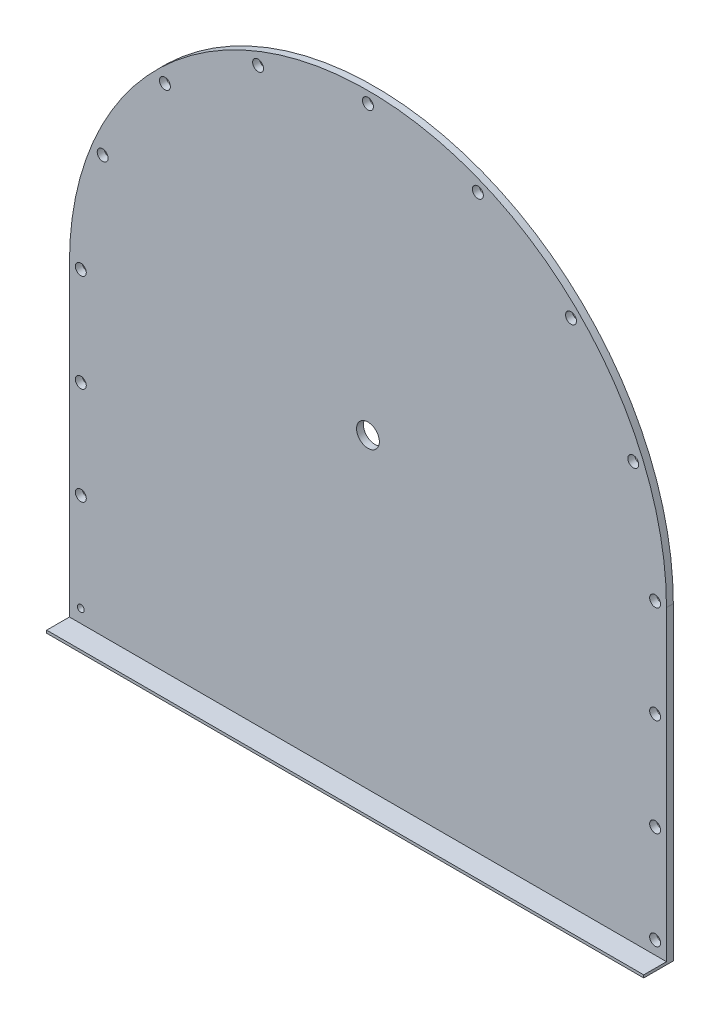
from build123d import *

# Parameters (mm, degrees)
EXTRUDE_1_DEPTH     = 1312
CUT_EXTRUDE_1_REACH = 17
SKETCH_2_R          = 25
CUT_EXTRUDE_2_REACH = 17
CUT_EXTRUDE_3_REACH = 17
SKETCH_4_R          = 7.5
SKETCH_4_R_2        = 12


with BuildPart() as part:
    # 스케치1 → 보스-돌출1 (new body)
    with BuildSketch(Plane(origin=(0, 0, 0), x_dir=(0, 0, -1), z_dir=(1, 0, 0))):
        Polygon((0, 0), (65, 0), (65, 1336), (50, 1336), (50, 6), (0, 6), align=None)
    extrude(amount=EXTRUDE_1_DEPTH)

    # 스케치2 → 컷-돌출1 (cut, up to next)
    with BuildSketch(Plane.XY.offset(-50), mode=Mode.PRIVATE) as cut_extrude_1_sk1:
        with Locations((656, 680)):
            Circle(SKETCH_2_R)
    cut_extrude_1_tool1 = extrude(cut_extrude_1_sk1.sketch, amount=-CUT_EXTRUDE_1_REACH, mode=Mode.PRIVATE) & part.part
    add(cut_extrude_1_tool1.solids().sort_by_distance((656, 680, -50))[0], mode=Mode.SUBTRACT)

    # 스케치3 → 컷-돌출2 (cut, up to next)
    with BuildSketch(Plane.XY.offset(-50), mode=Mode.PRIVATE) as cut_extrude_2_sk1:
        with BuildLine():
            ThreePointArc((0, 680), (192.137951542, 1143.862048458), (656, 1336))
            Line((656, 1336), (0, 1336))
            Line((0, 1336), (0, 680))
        make_face()
    cut_extrude_2_tool1 = extrude(cut_extrude_2_sk1.sketch, amount=-CUT_EXTRUDE_2_REACH, mode=Mode.PRIVATE) & part.part
    add(cut_extrude_2_tool1.solids().sort_by_distance((146.529368, 1189.470632, -50))[0], mode=Mode.SUBTRACT)
    # 스케치3 → 컷-돌출2 (cut, up to next)
    with BuildSketch(Plane.XY.offset(-50), mode=Mode.PRIVATE) as cut_extrude_2_sk2:
        with BuildLine():
            Line((1312, 680), (1312, 1336))
            Line((1312, 1336), (656, 1336))
            ThreePointArc((656, 1336), (1119.862048458, 1143.862048458), (1312, 680))
        make_face()
    cut_extrude_2_tool2 = extrude(cut_extrude_2_sk2.sketch, amount=-CUT_EXTRUDE_2_REACH, mode=Mode.PRIVATE) & part.part
    add(cut_extrude_2_tool2.solids().sort_by_distance((1165.470632, 1189.470632, -50))[0], mode=Mode.SUBTRACT)

    # 스케치4 → 컷-돌출3 (cut, up to next)
    with BuildSketch(Plane.XY.offset(-50), mode=Mode.PRIVATE) as cut_extrude_3_sk1:
        with Locations((25, 35)):
            Circle(SKETCH_4_R)
    cut_extrude_3_tool1 = extrude(cut_extrude_3_sk1.sketch, amount=-CUT_EXTRUDE_3_REACH, mode=Mode.PRIVATE) & part.part
    add(cut_extrude_3_tool1.solids().sort_by_distance((25, 35, -50))[0], mode=Mode.SUBTRACT)
    # 스케치4 → 컷-돌출3 (cut, up to next)
    with BuildSketch(Plane.XY.offset(-50), mode=Mode.PRIVATE) as cut_extrude_3_sk2:
        with Locations((25, 250)):
            Circle(SKETCH_4_R_2)
    cut_extrude_3_tool2 = extrude(cut_extrude_3_sk2.sketch, amount=-CUT_EXTRUDE_3_REACH, mode=Mode.PRIVATE) & part.part
    add(cut_extrude_3_tool2.solids().sort_by_distance((25, 250, -50))[0], mode=Mode.SUBTRACT)
    # 스케치4 → 컷-돌출3 (cut, up to next)
    with BuildSketch(Plane.XY.offset(-50), mode=Mode.PRIVATE) as cut_extrude_3_sk3:
        with Locations((25, 465)):
            Circle(SKETCH_4_R_2)
    cut_extrude_3_tool3 = extrude(cut_extrude_3_sk3.sketch, amount=-CUT_EXTRUDE_3_REACH, mode=Mode.PRIVATE) & part.part
    add(cut_extrude_3_tool3.solids().sort_by_distance((25, 465, -50))[0], mode=Mode.SUBTRACT)
    # 스케치4 → 컷-돌출3 (cut, up to next)
    with BuildSketch(Plane.XY.offset(-50), mode=Mode.PRIVATE) as cut_extrude_3_sk4:
        with Locations((25, 680)):
            Circle(SKETCH_4_R_2)
    cut_extrude_3_tool4 = extrude(cut_extrude_3_sk4.sketch, amount=-CUT_EXTRUDE_3_REACH, mode=Mode.PRIVATE) & part.part
    add(cut_extrude_3_tool4.solids().sort_by_distance((25, 680, -50))[0], mode=Mode.SUBTRACT)
    # 스케치4 → 컷-돌출3 (cut, up to next)
    with BuildSketch(Plane.XY.offset(-50), mode=Mode.PRIVATE) as cut_extrude_3_sk5:
        with Locations((73.032014985, 921.473245822)):
            Circle(SKETCH_4_R_2)
    cut_extrude_3_tool5 = extrude(cut_extrude_3_sk5.sketch, amount=-CUT_EXTRUDE_3_REACH, mode=Mode.PRIVATE) & part.part
    add(cut_extrude_3_tool5.solids().sort_by_distance((73.032015, 921.473246, -50))[0], mode=Mode.SUBTRACT)
    # 스케치4 → 컷-돌출3 (cut, up to next)
    with BuildSketch(Plane.XY.offset(-50), mode=Mode.PRIVATE) as cut_extrude_3_sk6:
        with Locations((209.815621071, 1126.184378929)):
            Circle(SKETCH_4_R_2)
    cut_extrude_3_tool6 = extrude(cut_extrude_3_sk6.sketch, amount=-CUT_EXTRUDE_3_REACH, mode=Mode.PRIVATE) & part.part
    add(cut_extrude_3_tool6.solids().sort_by_distance((209.815621, 1126.184379, -50))[0], mode=Mode.SUBTRACT)
    # 스케치4 → 컷-돌출3 (cut, up to next)
    with BuildSketch(Plane.XY.offset(-50), mode=Mode.PRIVATE) as cut_extrude_3_sk7:
        with Locations((414.526754178, 1262.967985015)):
            Circle(SKETCH_4_R_2)
    cut_extrude_3_tool7 = extrude(cut_extrude_3_sk7.sketch, amount=-CUT_EXTRUDE_3_REACH, mode=Mode.PRIVATE) & part.part
    add(cut_extrude_3_tool7.solids().sort_by_distance((414.526754, 1262.967985, -50))[0], mode=Mode.SUBTRACT)
    # 스케치4 → 컷-돌출3 (cut, up to next)
    with BuildSketch(Plane.XY.offset(-50), mode=Mode.PRIVATE) as cut_extrude_3_sk8:
        with Locations((656, 1311)):
            Circle(SKETCH_4_R_2)
    cut_extrude_3_tool8 = extrude(cut_extrude_3_sk8.sketch, amount=-CUT_EXTRUDE_3_REACH, mode=Mode.PRIVATE) & part.part
    add(cut_extrude_3_tool8.solids().sort_by_distance((656, 1311, -50))[0], mode=Mode.SUBTRACT)
    # 스케치4 → 컷-돌출3 (cut, up to next)
    with BuildSketch(Plane.XY.offset(-50), mode=Mode.PRIVATE) as cut_extrude_3_sk9:
        with Locations((897.473245822, 1262.967985015)):
            Circle(SKETCH_4_R_2)
    cut_extrude_3_tool9 = extrude(cut_extrude_3_sk9.sketch, amount=-CUT_EXTRUDE_3_REACH, mode=Mode.PRIVATE) & part.part
    add(cut_extrude_3_tool9.solids().sort_by_distance((897.473246, 1262.967985, -50))[0], mode=Mode.SUBTRACT)
    # 스케치4 → 컷-돌출3 (cut, up to next)
    with BuildSketch(Plane.XY.offset(-50), mode=Mode.PRIVATE) as cut_extrude_3_sk10:
        with Locations((1102.184378929, 1126.184378929)):
            Circle(SKETCH_4_R_2)
    cut_extrude_3_tool10 = extrude(cut_extrude_3_sk10.sketch, amount=-CUT_EXTRUDE_3_REACH, mode=Mode.PRIVATE) & part.part
    add(cut_extrude_3_tool10.solids().sort_by_distance((1102.184379, 1126.184379, -50))[0], mode=Mode.SUBTRACT)
    # 스케치4 → 컷-돌출3 (cut, up to next)
    with BuildSketch(Plane.XY.offset(-50), mode=Mode.PRIVATE) as cut_extrude_3_sk11:
        with Locations((1238.967985015, 921.473245822)):
            Circle(SKETCH_4_R_2)
    cut_extrude_3_tool11 = extrude(cut_extrude_3_sk11.sketch, amount=-CUT_EXTRUDE_3_REACH, mode=Mode.PRIVATE) & part.part
    add(cut_extrude_3_tool11.solids().sort_by_distance((1238.967985, 921.473246, -50))[0], mode=Mode.SUBTRACT)
    # 스케치4 → 컷-돌출3 (cut, up to next)
    with BuildSketch(Plane.XY.offset(-50), mode=Mode.PRIVATE) as cut_extrude_3_sk12:
        with Locations((1287, 680)):
            Circle(SKETCH_4_R_2)
    cut_extrude_3_tool12 = extrude(cut_extrude_3_sk12.sketch, amount=-CUT_EXTRUDE_3_REACH, mode=Mode.PRIVATE) & part.part
    add(cut_extrude_3_tool12.solids().sort_by_distance((1287, 680, -50))[0], mode=Mode.SUBTRACT)
    # 스케치4 → 컷-돌출3 (cut, up to next)
    with BuildSketch(Plane.XY.offset(-50), mode=Mode.PRIVATE) as cut_extrude_3_sk13:
        with Locations((1287, 465)):
            Circle(SKETCH_4_R_2)
    cut_extrude_3_tool13 = extrude(cut_extrude_3_sk13.sketch, amount=-CUT_EXTRUDE_3_REACH, mode=Mode.PRIVATE) & part.part
    add(cut_extrude_3_tool13.solids().sort_by_distance((1287, 465, -50))[0], mode=Mode.SUBTRACT)
    # 스케치4 → 컷-돌출3 (cut, up to next)
    with BuildSketch(Plane.XY.offset(-50), mode=Mode.PRIVATE) as cut_extrude_3_sk14:
        with Locations((1287, 250)):
            Circle(SKETCH_4_R_2)
    cut_extrude_3_tool14 = extrude(cut_extrude_3_sk14.sketch, amount=-CUT_EXTRUDE_3_REACH, mode=Mode.PRIVATE) & part.part
    add(cut_extrude_3_tool14.solids().sort_by_distance((1287, 250, -50))[0], mode=Mode.SUBTRACT)
    # 스케치4 → 컷-돌출3 (cut, up to next)
    with BuildSketch(Plane.XY.offset(-50), mode=Mode.PRIVATE) as cut_extrude_3_sk15:
        with Locations((1287, 35)):
            Circle(SKETCH_4_R_2)
    cut_extrude_3_tool15 = extrude(cut_extrude_3_sk15.sketch, amount=-CUT_EXTRUDE_3_REACH, mode=Mode.PRIVATE) & part.part
    add(cut_extrude_3_tool15.solids().sort_by_distance((1287, 35, -50))[0], mode=Mode.SUBTRACT)


solid = part.part
